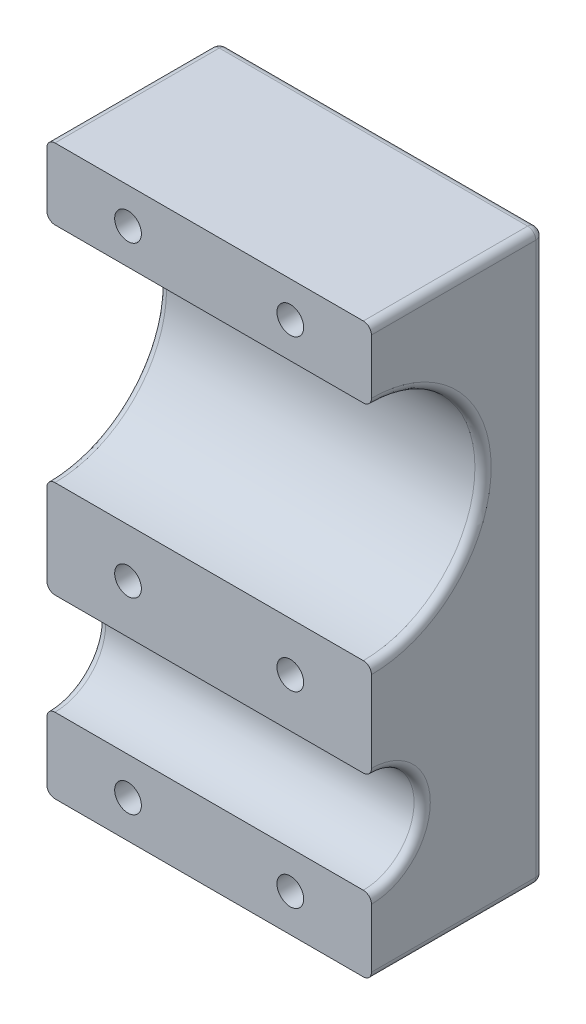
from build123d import *

# Parameters (mm, degrees)
SKETCH1_W           = 53.975
SKETCH1_H           = 88.9
SKETCH1_R           = 7.9375
SKETCH1_R_2         = 17.4625
BOSS_EXTRUDE1_DEPTH = 50.8
SKETCH5_R           = 2.09
CUT_EXTRUDE1_DEPTH  = 116.746060948
SKETCH5_3_R         = 3.6
CUT_EXTRUDE2_DEPTH  = 4.064
CUT_EXTRUDE3_DEPTH  = 2.54
FILLET1_R           = 1.27


with BuildPart() as part:
    # Sketch1 → Boss-Extrude1 (new body)
    with BuildSketch(Plane(origin=(0, 0, 0), x_dir=(0, 0, -1), z_dir=(1, 0, 0))):
        with Locations((26.9875, 44.45)):
            Rectangle(SKETCH1_W, SKETCH1_H)
        with Locations(Location((26.9875, 19.685, 0), (0, 0, 180))):
            Circle(SKETCH1_R, mode=Mode.SUBTRACT)
        with Locations(Location((26.9875, 60.325, 0), (0, 0, 180))):
            Circle(SKETCH1_R_2, mode=Mode.SUBTRACT)
    extrude(amount=BOSS_EXTRUDE1_DEPTH)

    # Sketch5 → Cut-Extrude1 (cut, through all)
    with BuildSketch(Plane.XY):
        with Locations((12.7, 83.34375)):
            Circle(SKETCH5_R)
        with Locations((12.7, 35.2425)):
            Circle(SKETCH5_R)
        with Locations((38.1, 83.34375)):
            Circle(SKETCH5_R)
        with Locations((38.1, 35.2425)):
            Circle(SKETCH5_R)
        with Locations((12.7, 5.87375)):
            Circle(SKETCH5_R)
        with Locations((38.1, 5.87375)):
            Circle(SKETCH5_R)
    extrude(amount=-CUT_EXTRUDE1_DEPTH, mode=Mode.SUBTRACT)

    # Sketch5_3 → Cut-Extrude2 (cut)
    with BuildSketch(Plane.XY):
        with Locations((38.1, 35.2425)):
            Circle(SKETCH5_3_R)
        with Locations((12.7, 83.34375)):
            Circle(SKETCH5_3_R)
        with Locations((38.1, 83.34375)):
            Circle(SKETCH5_3_R)
        with Locations((12.7, 35.2425)):
            Circle(SKETCH5_3_R)
        with Locations((38.1, 5.87375)):
            Circle(SKETCH5_3_R)
        with Locations((12.7, 5.87375)):
            Circle(SKETCH5_3_R)
    extrude(amount=-CUT_EXTRUDE2_DEPTH, mode=Mode.SUBTRACT)

    # Sketch6 → Cut-Extrude3 (cut)
    with BuildSketch(Plane(origin=(0, 0, -53.975), x_dir=(-1, 0, 0), z_dir=(0, 0, -1))):
        Polygon((-34.02855, 83.34375), (-36.064275, 86.86972913), (-40.135725, 86.86972913), (-42.17145, 83.34375), (-40.135725, 79.81777087), (-36.064275, 79.81777087), align=None)
        Polygon((-8.62855, 83.34375), (-10.664275, 86.86972913), (-14.735725, 86.86972913), (-16.77145, 83.34375), (-14.735725, 79.81777087), (-10.664275, 79.81777087), align=None)
        Polygon((-8.62855, 35.2425), (-10.664275, 38.76847913), (-14.735725, 38.76847913), (-16.77145, 35.2425), (-14.735725, 31.71652087), (-10.664275, 31.71652087), align=None)
        Polygon((-34.02855, 35.2425), (-36.064275, 38.76847913), (-40.135725, 38.76847913), (-42.17145, 35.2425), (-40.135725, 31.71652087), (-36.064275, 31.71652087), align=None)
        Polygon((-34.02855, 5.87375), (-36.064275, 9.39972913), (-40.135725, 9.39972913), (-42.17145, 5.87375), (-40.135725, 2.34777087), (-36.064275, 2.34777087), align=None)
        Polygon((-8.62855, 5.87375), (-10.664275, 9.39972913), (-14.735725, 9.39972913), (-16.77145, 5.87375), (-14.735725, 2.34777087), (-10.664275, 2.34777087), align=None)
    extrude(amount=-CUT_EXTRUDE3_DEPTH, mode=Mode.SUBTRACT)

    # Fillet1
    fillet1_edges = [part.edges().sort_by_distance(p)[0] for p in [
        (0, 60.325, -44.45),
        (50.8, 60.325, -44.45),
        (50.8, 88.9, -26.9875),
        (0, 19.685, -34.925),
        (50.8, 19.685, -34.925),
        (50.8, 44.45, 0),
        (50.8, 0, -26.9875),
        (0, 44.45, 0),
        (0, 88.9, -26.9875),
        (0, 44.45, -53.975),
        (0, 0, -26.9875),
        (25.4, 0, 0),
        (25.4, 88.9, 0),
        (25.4, 88.9, -53.975),
        (25.4, 0, -53.975),
        (50.8, 44.45, -53.975),
    ]]
    fillet(fillet1_edges, radius=FILLET1_R)

    # SurfaceCut1
    split(bisect_by=Plane.XY.offset(-26.9875), keep=Keep.BOTTOM)


solid = part.part
